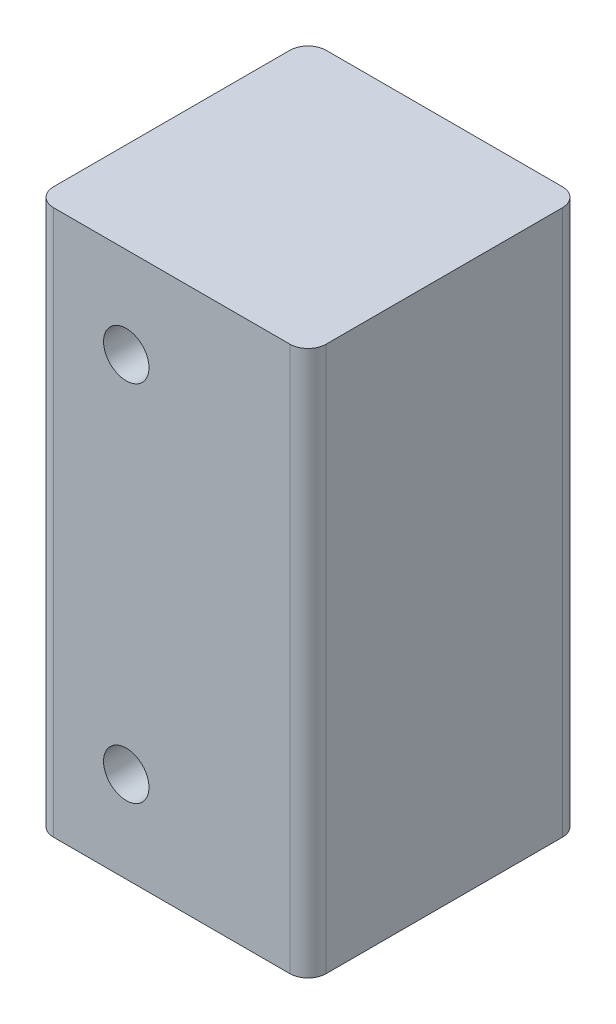
from build123d import *

# Parameters (mm, degrees)
ESQUISSE1_W      = 30
ESQUISSE1_H      = 60
ESQUISSE1_R      = 2.5
EXTRUSION1_DEPTH = 30
CONG_1_R         = 2


with BuildPart() as part:
    # Esquisse1 → Extrusion1 (new body)
    with BuildSketch(Plane.XY):
        with Locations((15, 30)):
            Rectangle(ESQUISSE1_W, ESQUISSE1_H)
        with Locations((10, 50)):
            Circle(ESQUISSE1_R, mode=Mode.SUBTRACT)
        with Locations((10, 10)):
            Circle(ESQUISSE1_R, mode=Mode.SUBTRACT)
    extrude(amount=EXTRUSION1_DEPTH)

    # Congé1
    cong_1_edges = [part.edges().sort_by_distance(p)[0] for p in [
        (30, 30, 30),
        (0, 30, 30),
        (30, 30, 0),
        (0, 30, 0),
    ]]
    fillet(cong_1_edges, radius=CONG_1_R)


solid = part.part
